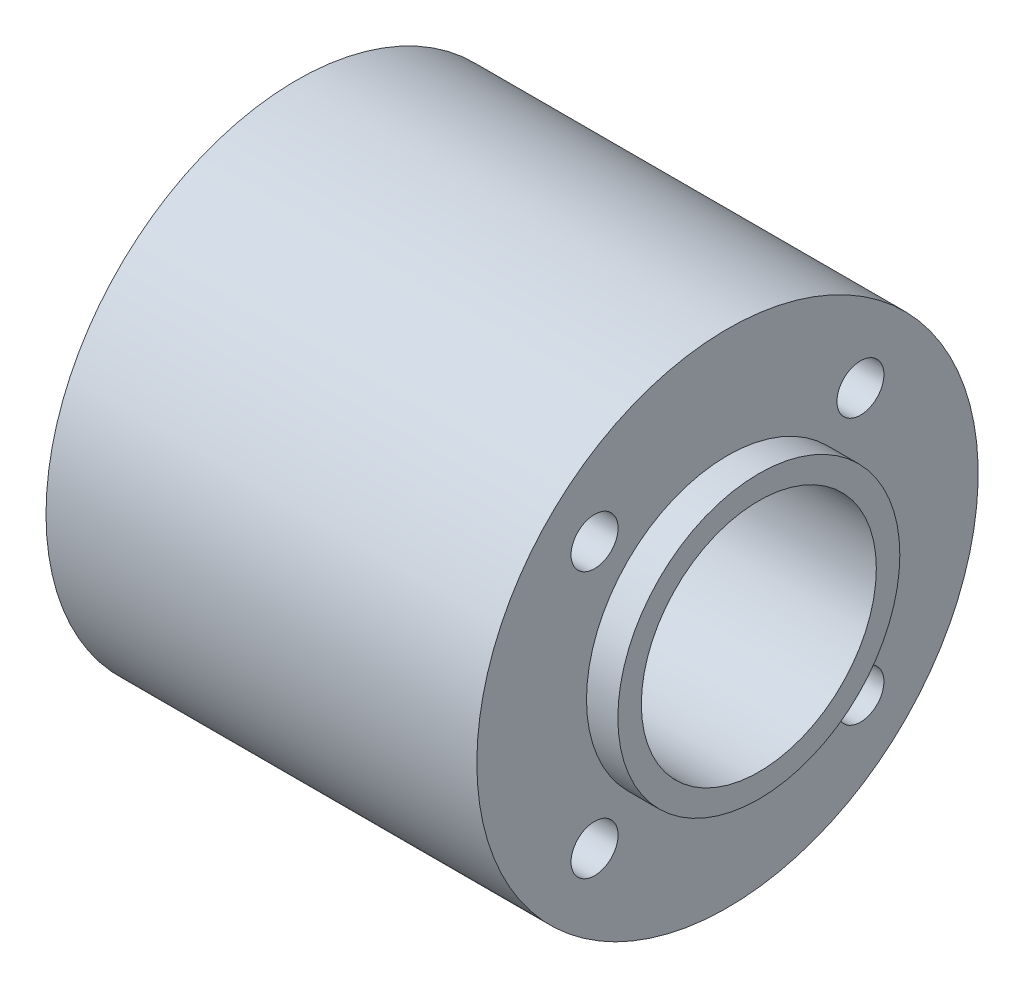
from build123d import *

# Parameters (mm, degrees)
SKETCH2_R          = 1.5
CUT_EXTRUDE1_DEPTH = 30.5
CIRPATTERN1_COUNT  = 4
SCALE1_SCALE       = 1.7


with BuildPart() as part:
    # Sketch1 → Revolve1 (revolve)
    with BuildSketch(Plane.XY):
        Polygon((0, 7.5), (0, 9), (2, 9), (2, 16), (29.5, 16), (29.5, 9), (31.5, 9), (31.5, 7.5), align=None)
    revolve(axis=Axis((0, 0, 0), (1, 0, 0)))

    # Sketch2 → Cut-Extrude1 (cut, through all)
    with BuildSketch(Plane.ZY.offset(-2)):
        with Locations((8.485281374, 8.485281374)):
            Circle(SKETCH2_R)
    cut_extrude1 = extrude(amount=-CUT_EXTRUDE1_DEPTH, mode=Mode.SUBTRACT)

    # CirPattern1: Cut-Extrude1 ×4 about axis
    cirpattern1_axis = Axis((0, 0, 0), (1, 0, 0))
    for i in range(1, CIRPATTERN1_COUNT):
        add(cut_extrude1.rotate(cirpattern1_axis, i * 360 / CIRPATTERN1_COUNT), mode=Mode.SUBTRACT)


with BuildPart() as part_1:
    # Scale1: scaled about (15.75, 0, 0)
    add(part.part.scale(SCALE1_SCALE).moved(Location((-11.025, 0, 0))))


solid = part_1.part
